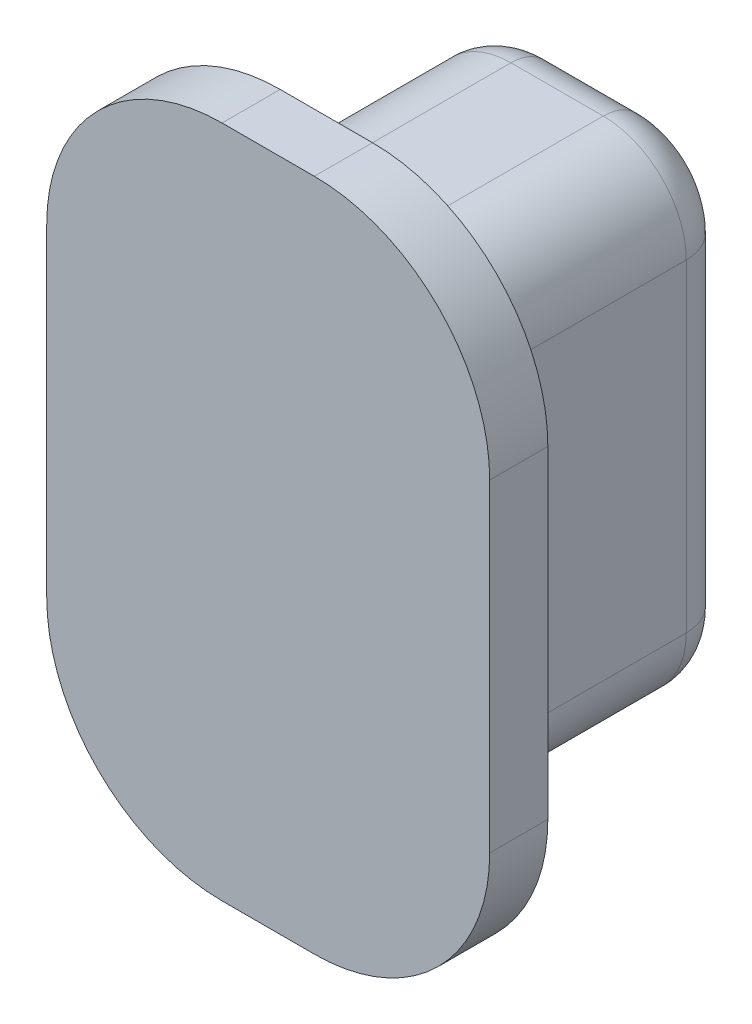
from build123d import *

# Parameters (mm, degrees)
BOSS_EXTRUDE1_DEPTH = 3
BOSS_EXTRUDE2_DEPTH = 0.63
FILLET1_R           = 0.5


with BuildPart() as part:
    # Sketch1 → Boss-Extrude1 (new body)
    with BuildSketch(Plane.XY):
        with BuildLine():
            Line((-3.5, 18.4), (-2.5, 18.4))
            ThreePointArc((-2.5, 18.4), (-1.863603897, 18.663603897), (-1.6, 19.3))
            Line((-1.6, 19.3), (-1.6, 22.8))
            ThreePointArc((-1.6, 22.8), (-1.863603897, 23.436396103), (-2.5, 23.7))
            Line((-2.5, 23.7), (-3.5, 23.7))
            ThreePointArc((-3.5, 23.7), (-4.136396103, 23.436396103), (-4.4, 22.8))
            Line((-4.4, 22.8), (-4.4, 19.3))
            ThreePointArc((-4.4, 19.3), (-4.136396103, 18.663603897), (-3.5, 18.4))
        make_face()
    extrude(amount=-BOSS_EXTRUDE1_DEPTH)

    # Sketch2 → Boss-Extrude2 (add)
    with BuildSketch(Plane.XY):
        with BuildLine():
            Line((-3.5, 17.4), (-2.5, 17.4))
            ThreePointArc((-2.5, 17.4), (-1.156497116, 17.956497116), (-0.6, 19.3))
            Line((-0.6, 19.3), (-0.6, 22.8))
            ThreePointArc((-0.6, 22.8), (-1.156497116, 24.143502884), (-2.5, 24.7))
            Line((-2.5, 24.7), (-3.5, 24.7))
            ThreePointArc((-3.5, 24.7), (-4.843502884, 24.143502884), (-5.4, 22.8))
            Line((-5.4, 22.8), (-5.4, 19.3))
            ThreePointArc((-5.4, 19.3), (-4.843502884, 17.956497116), (-3.5, 17.4))
        make_face()
    extrude(amount=BOSS_EXTRUDE2_DEPTH)

    # Fillet1
    fillet1_edges = [part.edges().sort_by_distance(p)[0] for p in [
        (-3, 18.4, -3),
        (-1.863603897, 18.663603897, -3),
        (-1.6, 21.05, -3),
        (-1.863603897, 23.436396103, -3),
        (-3, 23.7, -3),
        (-4.136396103, 23.436396103, -3),
        (-4.4, 21.05, -3),
        (-4.136396103, 18.663603897, -3),
    ]]
    fillet(fillet1_edges, radius=FILLET1_R)


solid = part.part
